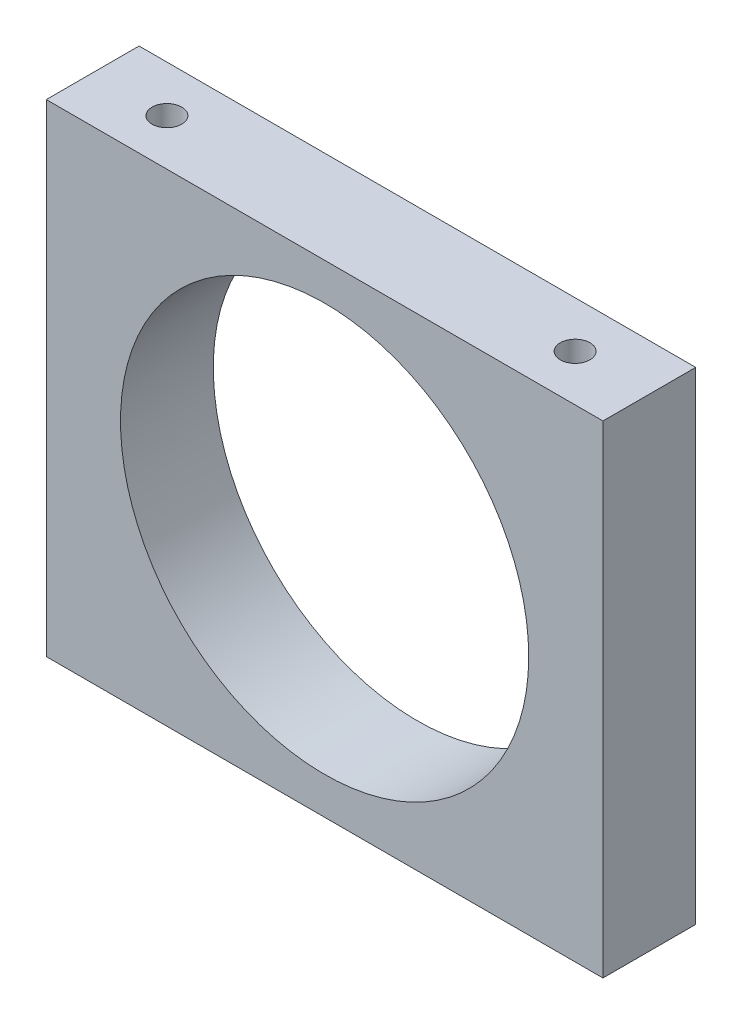
from build123d import *

# Parameters (mm, degrees)
ESQUISSE1_W                                   = 30
ESQUISSE1_H                                   = 26
ESQUISSE1_R                                   = 11
BOSS_EXTRU_1_DEPTH                            = 5
TROU_POUR_TARAUDAGE_POUR_TROU_TARAUD_M2_D     = 1.6
TROU_POUR_TARAUDAGE_POUR_TROU_TARAUD_M2_DEPTH = 5
TROU_POUR_TARAUDAGE_POUR_TROU_TARAUD_M2_TIP   = 0.480688495
TROU_POUR_TARAUDAGE_POUR_TROU_TARAUD_2_D      = 1.6
TROU_POUR_TARAUDAGE_POUR_TROU_TARAUD_2_DEPTH  = 5
TROU_POUR_TARAUDAGE_POUR_TROU_TARAUD_2_TIP    = 0.480688495


with BuildPart() as part:
    # Esquisse1 → Boss.-Extru.1 (new body)
    with BuildSketch(Plane.XY):
        with Locations((15, 13)):
            Rectangle(ESQUISSE1_W, ESQUISSE1_H)
        with Locations((15, 13)):
            Circle(ESQUISSE1_R, mode=Mode.SUBTRACT)
    extrude(amount=BOSS_EXTRU_1_DEPTH)

    # Trou pour taraudage pour trou taraud_ M2
    with Locations(Plane(origin=(0, 26, 0), x_dir=(1, 0, 0), z_dir=(0, 1, 0))):
        with Locations((4, -2.5), (26, -2.5)):
            Hole(TROU_POUR_TARAUDAGE_POUR_TROU_TARAUD_M2_D / 2, depth=TROU_POUR_TARAUDAGE_POUR_TROU_TARAUD_M2_DEPTH)
            with Locations((0, 0, -(TROU_POUR_TARAUDAGE_POUR_TROU_TARAUD_M2_DEPTH + TROU_POUR_TARAUDAGE_POUR_TROU_TARAUD_M2_TIP / 2))):  # 118° drill point
                Cone(0, TROU_POUR_TARAUDAGE_POUR_TROU_TARAUD_M2_D / 2, TROU_POUR_TARAUDAGE_POUR_TROU_TARAUD_M2_TIP, mode=Mode.SUBTRACT)

    # Trou pour taraudage pour trou taraud 2
    with Locations(Plane(origin=(0, 0, 0), x_dir=(-1, 0, 0), z_dir=(0, -1, 0))):
        with Locations((-4, -2.5), (-26, -2.5)):
            Hole(TROU_POUR_TARAUDAGE_POUR_TROU_TARAUD_2_D / 2, depth=TROU_POUR_TARAUDAGE_POUR_TROU_TARAUD_2_DEPTH)
            with Locations((0, 0, -(TROU_POUR_TARAUDAGE_POUR_TROU_TARAUD_2_DEPTH + TROU_POUR_TARAUDAGE_POUR_TROU_TARAUD_2_TIP / 2))):  # 118° drill point
                Cone(0, TROU_POUR_TARAUDAGE_POUR_TROU_TARAUD_2_D / 2, TROU_POUR_TARAUDAGE_POUR_TROU_TARAUD_2_TIP, mode=Mode.SUBTRACT)


solid = part.part
